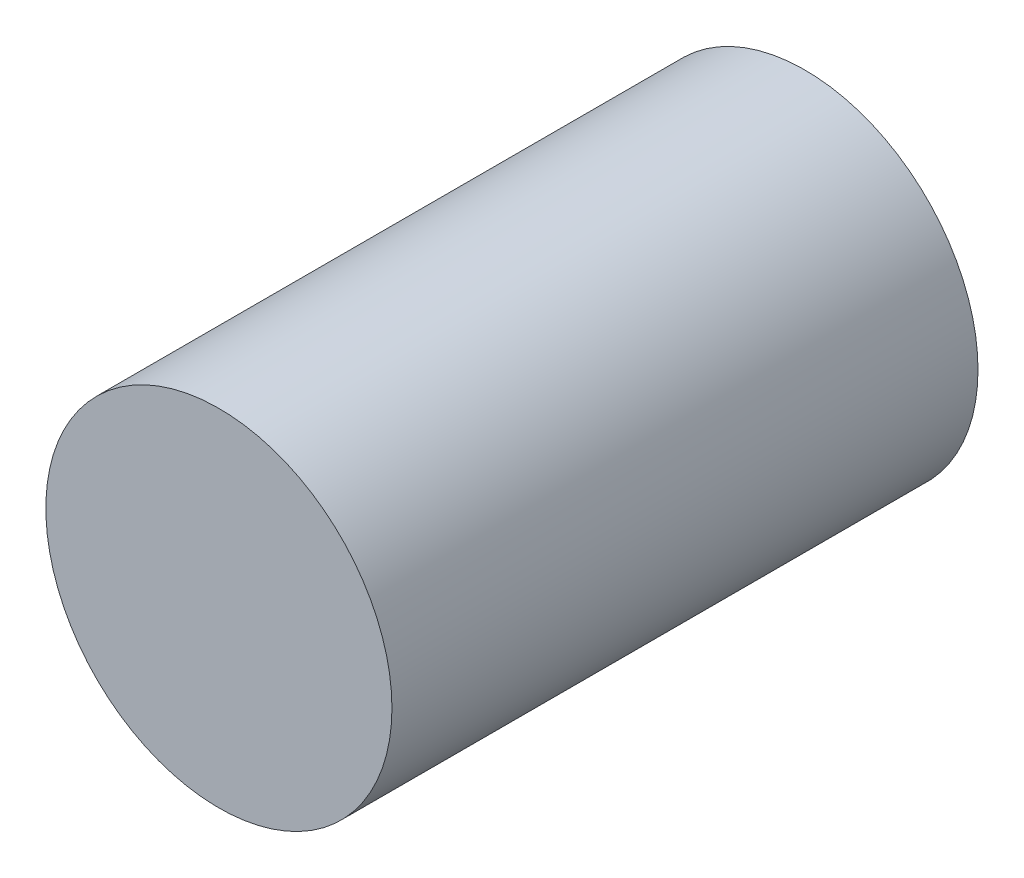
from build123d import *

# Parameters (mm, degrees)
SKETCH1_R           = 7.5
BOSS_EXTRUDE1_DEPTH = 25.4


with BuildPart() as part:
    # Sketch1 → Boss-Extrude1 (new body)
    with BuildSketch(Plane.XY):
        Circle(SKETCH1_R)
    extrude(amount=BOSS_EXTRUDE1_DEPTH)


solid = part.part
